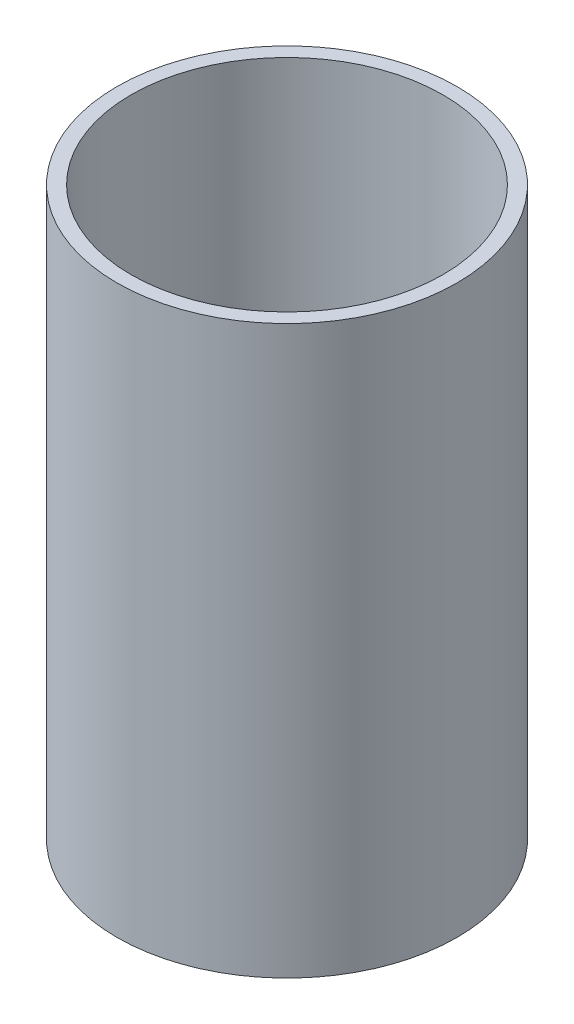
from build123d import *

# Parameters (mm, degrees)
SKETCH_1_R      = 6
SKETCH_1_R_2    = 5.5
EXTRUDE_1_DEPTH = 20


with BuildPart() as part:
    # 草图1 → 凸台-拉伸1 (new body)
    with BuildSketch(Plane(origin=(0, 0, 0), x_dir=(1, 0, 0), z_dir=(0, 1, 0))):
        Circle(SKETCH_1_R)
        Circle(SKETCH_1_R_2, mode=Mode.SUBTRACT)
    extrude(amount=EXTRUDE_1_DEPTH)


solid = part.part
